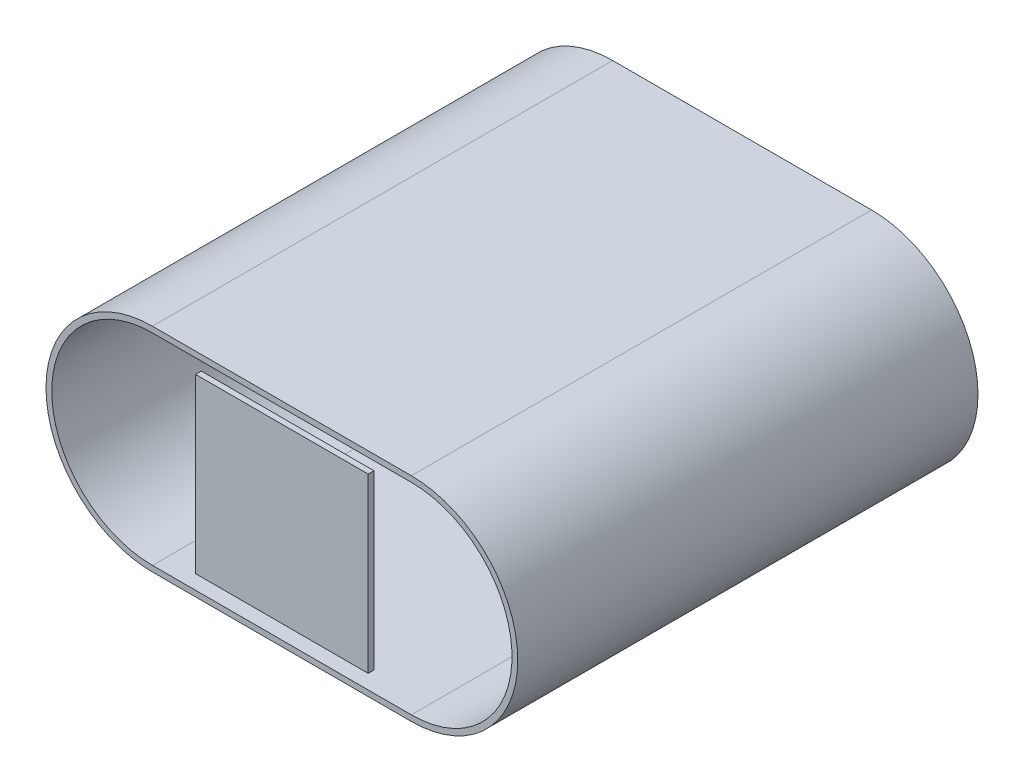
from build123d import *

# Parameters (mm, degrees)
SKETCH1_W           = 45
SKETCH1_H           = 37
BOSS_EXTRUDE1_DEPTH = 80
SHELL1_T            = -1
SKETCH2_W           = 45
SKETCH2_H           = 35
BOSS_EXTRUDE2_DEPTH = 1
SKETCH3_R           = 1.25
BOSS_EXTRUDE3_DEPTH = 15
SKETCH6_W           = 45
SKETCH6_H           = 35
BOSS_EXTRUDE4_DEPTH = 1
SKETCH7_W           = 30
SKETCH7_H           = 30
BOSS_EXTRUDE5_DEPTH = 1


with BuildPart() as part:
    # Sketch1 → Boss-Extrude1 (new body)
    with BuildSketch(Plane.XY):
        Rectangle(SKETCH1_W, SKETCH1_H)
        with BuildLine():
            ThreePointArc((22.5, 18.5), (41, 0), (22.5, -18.5))
            Line((22.5, -18.5), (22.5, 18.5))
        make_face()
        with BuildLine():
            Line((-22.5, -18.5), (-22.5, 18.5))
            ThreePointArc((-22.5, 18.5), (-41, 0), (-22.5, -18.5))
        make_face()
    extrude(amount=BOSS_EXTRUDE1_DEPTH)

    # Shell1
    shell1_openings = [part.faces().sort_by_distance(p)[0] for p in [
        (0, 0, 80),
    ]]
    offset(amount=SHELL1_T, openings=shell1_openings, kind=Kind.INTERSECTION)



with BuildPart() as body_2:
    # Sketch2 → Boss-Extrude2 (new body)
    with BuildSketch(Plane(origin=(0, 0, 0), x_dir=(-1, 0, 0), z_dir=(0, 0, -1))):
        Rectangle(SKETCH2_W, SKETCH2_H)
    extrude(amount=-BOSS_EXTRUDE2_DEPTH)


with BuildPart() as part_1:
    add(part.part)

    add(body_2.part)  # Boss-Extrude3 merges body 2
    # Sketch3 → Boss-Extrude3 (add)
    with BuildSketch(Plane(origin=(0, 0, 0), x_dir=(-1, 0, 0), z_dir=(0, 0, -1))):
        Circle(SKETCH3_R)
    extrude(amount=BOSS_EXTRUDE3_DEPTH)

    # Sketch5 → Revolve1 (revolve)
    with BuildSketch(Plane(origin=(0, 0, -15), x_dir=(-1, 0, 0), z_dir=(0, 0, -1))):
        with BuildLine():
            Line((0, 2.498582247), (0, -2.498582247))
            ThreePointArc((0, -2.498582247), (-2.498582247, 0), (0, 2.498582247))
        make_face()
    revolve(axis=Axis((0, 2.498582247, -15), (0, -1, 0)))


with BuildPart() as body_2_2:
    # Sketch6 → Boss-Extrude4 (new body)
    with BuildSketch(Plane(origin=(0, 0, 0), x_dir=(-1, 0, 0), z_dir=(0, 0, -1))):
        Rectangle(SKETCH6_W, SKETCH6_H)
    extrude(amount=-BOSS_EXTRUDE4_DEPTH)


with BuildPart() as body_3:
    # Sketch7 → Boss-Extrude5 (new body)
    with BuildSketch(Plane.XY.offset(80)):
        Rectangle(SKETCH7_W, SKETCH7_H)
    extrude(amount=-BOSS_EXTRUDE5_DEPTH)


solid = Compound([part_1.part, body_2_2.part, body_3.part])
